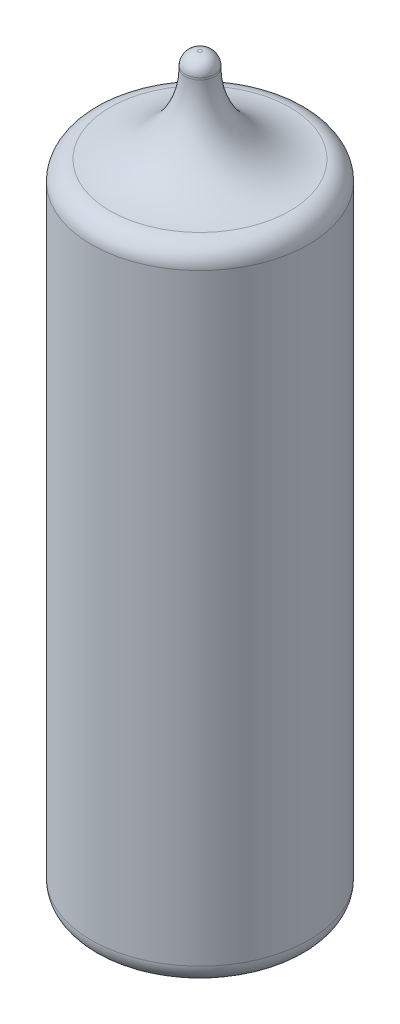
from build123d import *

# Parameters (mm, degrees)
SKETCH1_R           = 11
BOSS_EXTRUDE1_DEPTH = 65
SKETCH2_R           = 1.5
BOSS_EXTRUDE2_DEPTH = 9.5
FILLET1_R           = 1.3
FILLET2_R           = 8
FILLET3_R           = 2
FILLET4_R           = 2


with BuildPart() as part:
    # Sketch1 → Boss-Extrude1 (new body)
    with BuildSketch(Plane(origin=(0, 0, 0), x_dir=(1, 0, 0), z_dir=(0, 1, 0))):
        Circle(SKETCH1_R)
    extrude(amount=BOSS_EXTRUDE1_DEPTH)

    # Sketch2 → Boss-Extrude2 (add)
    with BuildSketch(Plane(origin=(0, 65, 0), x_dir=(1, 0, 0), z_dir=(0, 1, 0))):
        Circle(SKETCH2_R)
    extrude(amount=BOSS_EXTRUDE2_DEPTH)

    # Fillet1
    fillet1_edges = [part.edges().sort_by_distance(p)[0] for p in [
        (-1.5, 74.5, 0),
    ]]
    fillet(fillet1_edges, radius=FILLET1_R)

    # Fillet2
    fillet2_edges = [part.edges().sort_by_distance(p)[0] for p in [
        (-1.5, 65, 0),
    ]]
    fillet(fillet2_edges, radius=FILLET2_R)

    # Fillet3
    fillet3_edges = [part.edges().sort_by_distance(p)[0] for p in [
        (-11, 65, 0),
    ]]
    fillet(fillet3_edges, radius=FILLET3_R)

    # Fillet4
    fillet4_edges = [part.edges().sort_by_distance(p)[0] for p in [
        (-11, 0, 0),
    ]]
    fillet(fillet4_edges, radius=FILLET4_R)


solid = part.part
